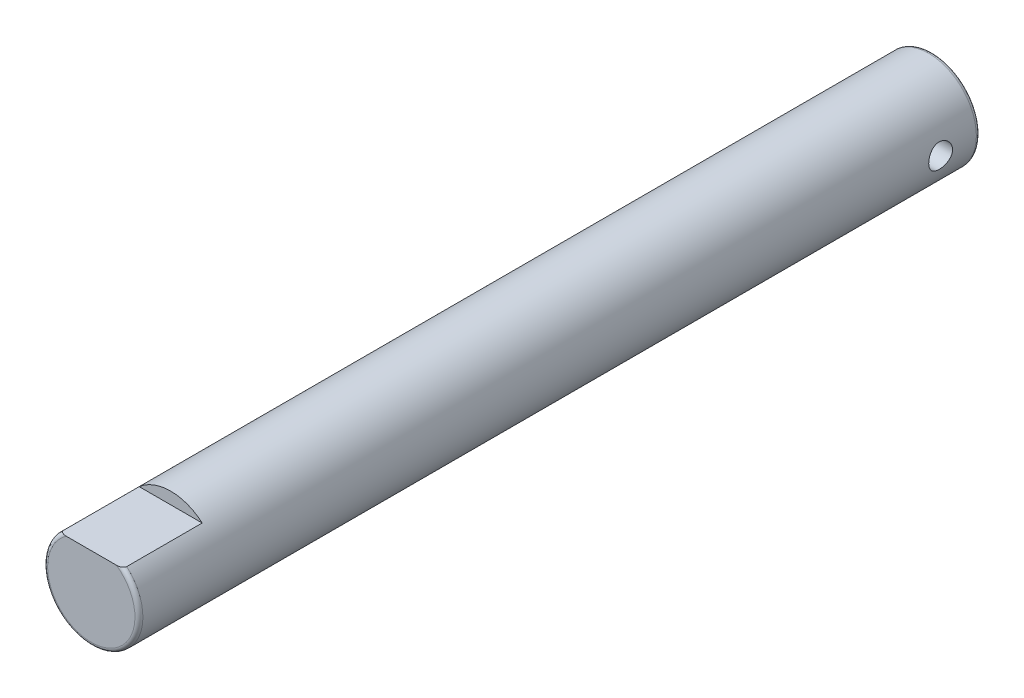
from build123d import *

# Parameters (mm, degrees)
SKETCH1_R               = 3
BOSS_EXTRUDE1_DEPTH     = 53
FILLET1_R               = 0.25
SKETCH2_R               = 0.75
CUT_EXTRUDE1_DEPTH      = 4.0000001
CUT_EXTRUDE1_DEPTH_BACK = 4.0000001
SKETCH4_W               = 15
SKETCH4_H               = 5
CUT_EXTRUDE2_DEPTH      = 53


with BuildPart() as part:
    # Sketch1 → Boss-Extrude1 (new body)
    with BuildSketch(Plane.XY):
        Circle(SKETCH1_R)
    extrude(amount=BOSS_EXTRUDE1_DEPTH)

    # Fillet1
    fillet1_edges = [part.edges().sort_by_distance(p)[0] for p in [
        (-3, 0, 0),
        (-3, 0, 53),
    ]]
    fillet(fillet1_edges, radius=FILLET1_R)

    # Sketch2 → Cut-Extrude1 (cut, two sides)
    with BuildSketch(Plane(origin=(0, 0, 0), x_dir=(0, 0, -1), z_dir=(1, 0, 0))) as cut_extrude1_sk:
        with Locations((-2.5, 0)):
            Circle(SKETCH2_R)
    extrude(amount=CUT_EXTRUDE1_DEPTH, mode=Mode.SUBTRACT)
    extrude(cut_extrude1_sk.sketch, amount=-CUT_EXTRUDE1_DEPTH_BACK, mode=Mode.SUBTRACT)

    # Sketch4 → Cut-Extrude2 (cut)
    with BuildSketch(Plane(origin=(0, 2.25, 0), x_dir=(1, 0, 0), z_dir=(0, 1, 0))):
        with Locations((0.79883006, -50.5)):
            Rectangle(SKETCH4_W, SKETCH4_H)
    extrude(amount=CUT_EXTRUDE2_DEPTH, mode=Mode.SUBTRACT)


solid = part.part
